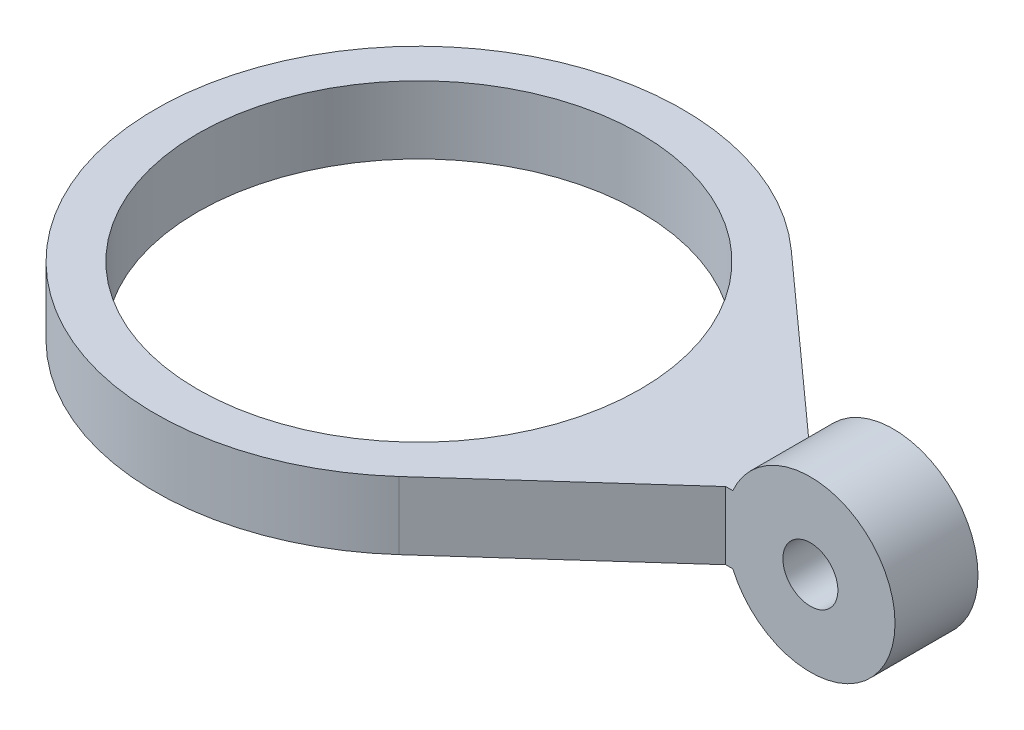
from build123d import *

# Parameters (mm, degrees)
CROQUIS1_R              = 15.575
CROQUIS1_R_2            = 13.075
SALIENTE_EXTRUIR1_DEPTH = 4
SALIENTE_EXTRUIR2_DEPTH = 4
SALIENTE_EXTRUIR3_DEPTH = 2.45
CROQUIS4_R              = 1.625
CORTAR_EXTRUIR1_DEPTH   = 19.025


with BuildPart() as part:
    # Croquis1 → Saliente-Extruir1 (new body)
    with BuildSketch(Plane(origin=(0, 0, 0), x_dir=(1, 0, 0), z_dir=(0, 1, 0))):
        Circle(CROQUIS1_R)
        Circle(CROQUIS1_R_2, mode=Mode.SUBTRACT)
    extrude(amount=SALIENTE_EXTRUIR1_DEPTH)

    # Croquis2 → Saliente-Extruir2 (add)
    with BuildSketch(Plane(origin=(0, 0, 0), x_dir=(1, 0, 0), z_dir=(0, 1, 0))):
        with BuildLine():
            Line((20.575, 2.45), (10.410630983, 11.584445932))
            ThreePointArc((10.410630983, 11.584445932), (15.575, 0), (10.410630983, -11.584445932))
            Line((10.410630983, -11.584445932), (20.575, -2.45))
            Line((20.575, -2.45), (20.575, 2.45))
        make_face()
    extrude(amount=SALIENTE_EXTRUIR2_DEPTH)

    # Croquis3 → Saliente-Extruir3 (add, symmetric)
    with BuildSketch(Plane.XY):
        with BuildLine():
            Line((20.575, 4), (20.575, 0))
            Line((20.575, 0), (20.992424305, 0))
            ThreePointArc((20.992424305, 0), (30.575, 2), (20.992424305, 4))
            Line((20.992424305, 4), (20.575, 4))
        make_face()
    extrude(amount=SALIENTE_EXTRUIR3_DEPTH, both=True)

    # Croquis4 → Cortar-Extruir1 (cut, through all)
    with BuildSketch(Plane.XY.offset(2.45)):
        with Locations((25.575, 2)):
            Circle(CROQUIS4_R)
    extrude(amount=-CORTAR_EXTRUIR1_DEPTH, mode=Mode.SUBTRACT)


solid = part.part
